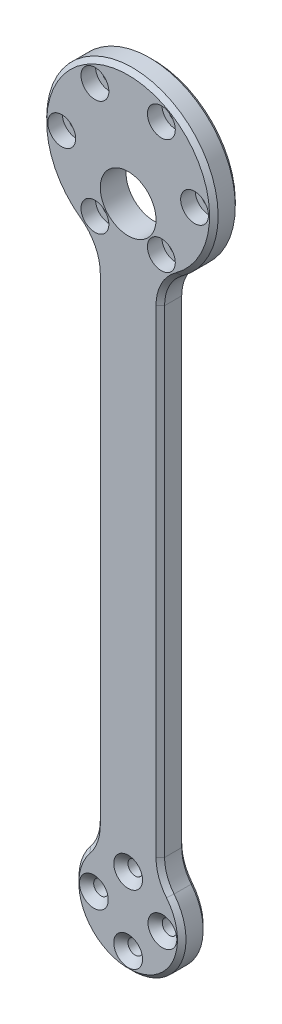
from build123d import *

# Parameters (mm, degrees)
SKETCH1_R                                            = 20
SKETCH1_R_2                                          = 12.5
SKETCH1_W                                            = 15
SKETCH1_H                                            = 150
BOSS_EXTRUDE1_DEPTH                                  = 6
SKETCH2_R                                            = 6.5
CUT_EXTRUDE1_DEPTH                                   = 6
FILLET1_R                                            = 10
CBORE_FOR_M3_HEX_SOCKET_HEAD_CAP_SCREW2_D            = 3.4
CBORE_FOR_M3_HEX_SOCKET_HEAD_CAP_SCREW2_CBORE_D      = 6.5
CBORE_FOR_M3_HEX_SOCKET_HEAD_CAP_SCREW2_CBORE_DEPTH  = 3.4
CIRPATTERN1_COUNT                                    = 6
CSK_FOR_M3_HEX_SOCKET_COUNTERSUNK_CAP_SC_D           = 3.4
CSK_FOR_M3_HEX_SOCKET_COUNTERSUNK_CAP_SC_CSINK_D     = 6.72
CSK_FOR_M3_HEX_SOCKET_COUNTERSUNK_CAP_SC_CSINK_ANGLE = 90
CHAMFER1_SIZE                                        = 1


with BuildPart() as part:
    # Sketch1 → Boss-Extrude1 (new body)
    with BuildSketch(Plane.XY):
        with Locations((0, 75)):
            Circle(SKETCH1_R)
        with Locations((0, -75)):
            Circle(SKETCH1_R_2)
        Rectangle(SKETCH1_W, SKETCH1_H)
    extrude(amount=BOSS_EXTRUDE1_DEPTH)

    # Sketch2 → Cut-Extrude1 (cut)
    with BuildSketch(Plane.XY.offset(6)):
        with Locations((0, 68)):
            Circle(SKETCH2_R)
    extrude(amount=-CUT_EXTRUDE1_DEPTH, mode=Mode.SUBTRACT)

    # Fillet1
    fillet1_edges = [part.edges().sort_by_distance(p)[0] for p in [
        (7.5, 56.459503782, 3),
        (7.5, -65, 3),
        (-7.5, -65, 3),
        (-7.5, 56.459503782, 3),
    ]]
    fillet(fillet1_edges, radius=FILLET1_R)

    # CBORE for M3 Hex Socket Head Cap Screw2 (through all)
    with Locations(Plane(origin=(15.5, 75, 6), x_dir=(1, 0, 0), z_dir=(0, 0, 1))):
        with Locations((0, 0)):
            cbore_for_m3_hex_socket_head_cap_screw2 = CounterBoreHole(CBORE_FOR_M3_HEX_SOCKET_HEAD_CAP_SCREW2_D / 2, CBORE_FOR_M3_HEX_SOCKET_HEAD_CAP_SCREW2_CBORE_D / 2, CBORE_FOR_M3_HEX_SOCKET_HEAD_CAP_SCREW2_CBORE_DEPTH)

    # CirPattern1: CBORE for M3 Hex Socket Head Cap Screw2 ×6 about axis
    cirpattern1_axis = Axis((0, 75, 0), (0, 0, 1))
    for i in range(1, CIRPATTERN1_COUNT):
        add(cbore_for_m3_hex_socket_head_cap_screw2.rotate(cirpattern1_axis, i * 360 / CIRPATTERN1_COUNT), mode=Mode.SUBTRACT)

    # CSK for M3 Hex Socket Countersunk Cap Sc (through all)
    with Locations(Plane(origin=(0, -67, 6), x_dir=(1, 0, 0), z_dir=(0, 0, 1))):
        with Locations((0, 0), (8, -8), (0, -16), (-8, -8)):
            CounterSinkHole(CSK_FOR_M3_HEX_SOCKET_COUNTERSUNK_CAP_SC_D / 2, CSK_FOR_M3_HEX_SOCKET_COUNTERSUNK_CAP_SC_CSINK_D / 2, counter_sink_angle=CSK_FOR_M3_HEX_SOCKET_COUNTERSUNK_CAP_SC_CSINK_ANGLE)

    # Chamfer1
    chamfer1_edges = [part.edges().sort_by_distance(p)[0] for p in [
        (7.5, -5.112425119, 0),
        (7.5, -5.112425119, 6),
        (0, -87.5, 0),
        (0, -87.5, 6),
        (-7.5, -5.112425119, 0),
        (-7.5, -5.112425119, 6),
        (0, 95, 0),
        (0, 95, 6),
        (8.071909584, -64.19119771, 0),
        (8.071909584, -64.19119771, 6),
        (-8.071909584, -64.19119771, 0),
        (-8.071909584, -64.19119771, 6),
        (-8.60243479, 55.197368784, 0),
        (-8.60243479, 55.197368784, 6),
        (8.60243479, 55.197368784, 0),
        (8.60243479, 55.197368784, 6),
    ]]
    chamfer(chamfer1_edges, length=CHAMFER1_SIZE)


solid = part.part
